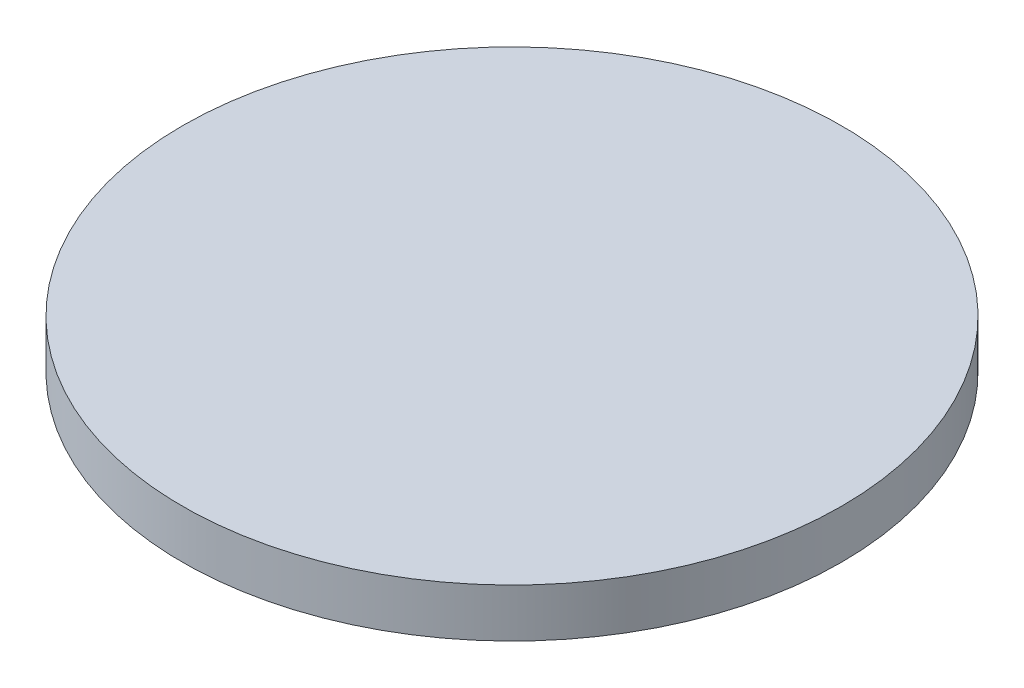
from build123d import *

# Parameters (mm, degrees)
SKETCH3_W = 55
SKETCH3_H = 8.1


with BuildPart() as part:
    # Sketch3 → Filter 2 (revolve)
    with BuildSketch(Plane.XY):
        with Locations((-27.5, 4.05)):
            Rectangle(SKETCH3_W, SKETCH3_H)
    revolve(axis=Axis((0, 0, 0), (0, 1, 0)))


solid = part.part
